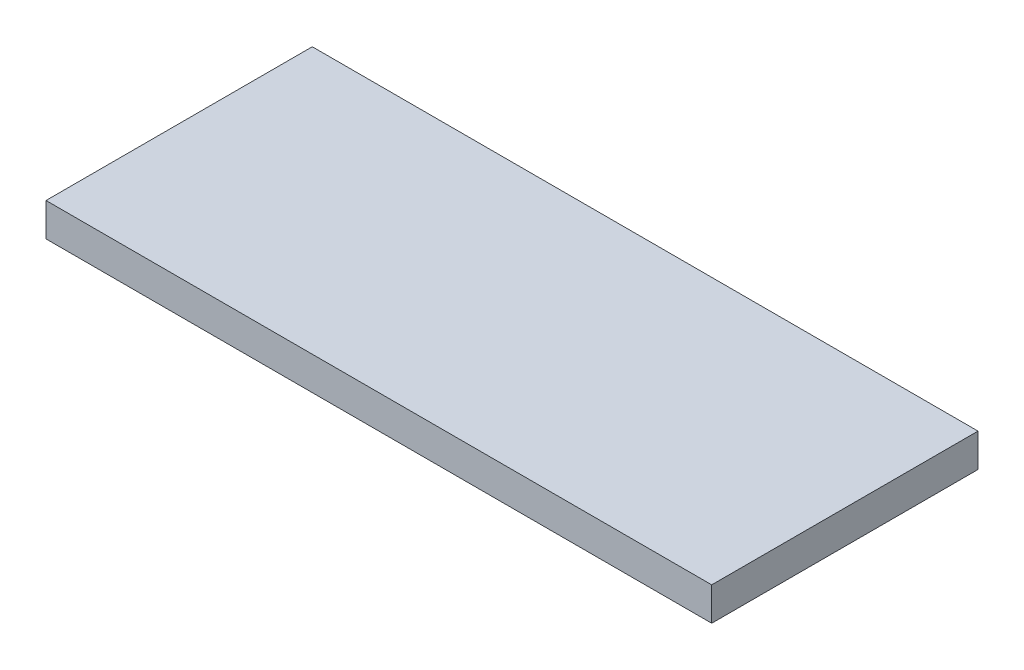
from build123d import *

# Parameters (mm, degrees)
SKETCH1_W           = 80
SKETCH1_H           = 32
BOSS_EXTRUDE1_DEPTH = 4


with BuildPart() as part:
    # Sketch1 → Boss-Extrude1 (new body)
    with BuildSketch(Plane(origin=(0, 0, 0), x_dir=(1, 0, 0), z_dir=(0, 1, 0))):
        Rectangle(SKETCH1_W, SKETCH1_H)
    extrude(amount=BOSS_EXTRUDE1_DEPTH)


solid = part.part
